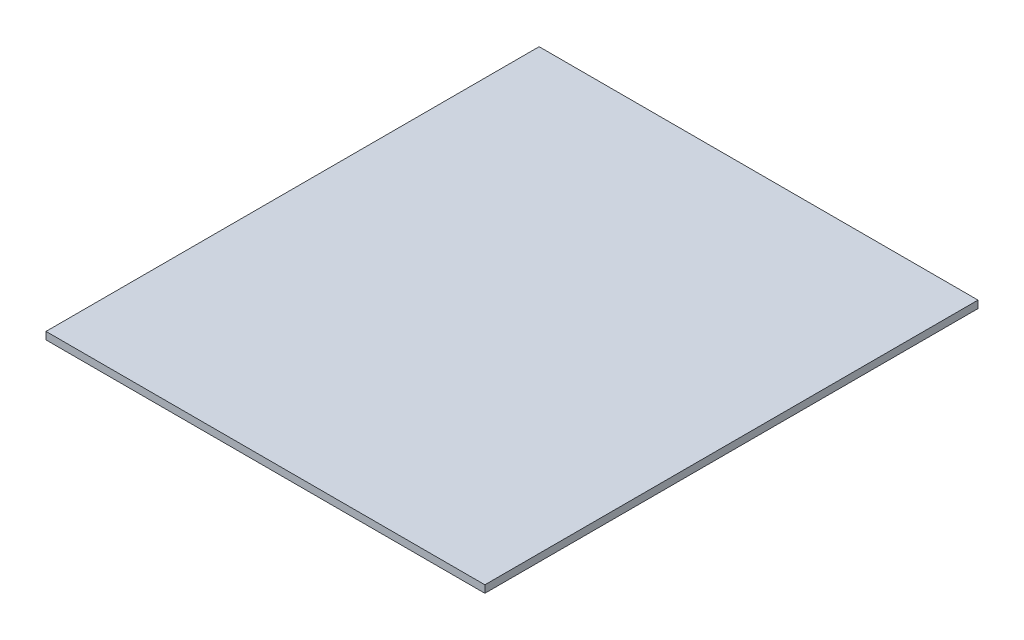
from build123d import *

# Parameters (mm, degrees)
ESBO_O1_W                = 178
ESBO_O1_H                = 200
RESSALTO_EXTRUS_O1_DEPTH = 3


with BuildPart() as part:
    # Esboço1 → Ressalto-extrusão1 (new body)
    with BuildSketch(Plane(origin=(0, 0, 0), x_dir=(1, 0, 0), z_dir=(0, 1, 0))):
        Rectangle(ESBO_O1_W, ESBO_O1_H)
    extrude(amount=RESSALTO_EXTRUS_O1_DEPTH)


solid = part.part
